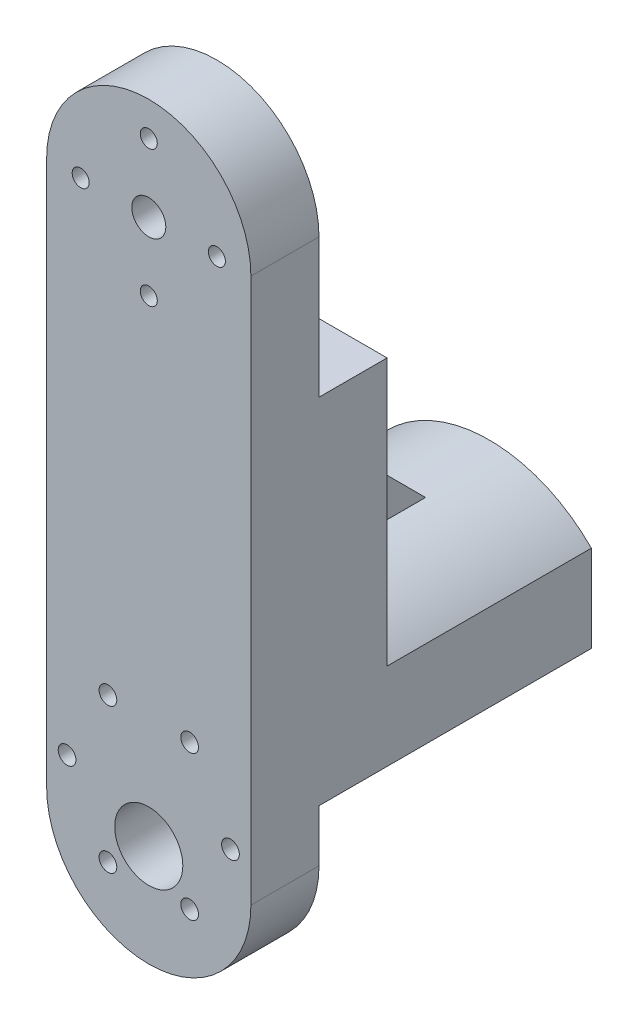
from build123d import *

# Parameters (mm, degrees)
SKETCH1_R           = 3.175
SKETCH1_R_2         = 6.35
SKETCH1_R_3         = 1.5875
BOSS_EXTRUDE1_DEPTH = 25.4
CUT_EXTRUDE1_REACH  = 40.1
SKETCH2_W           = 12.7
SKETCH2_H           = 44.958
CUT_EXTRUDE2_REACH  = 27.4
SKETCH3_R           = 1.651
BOSS_EXTRUDE2_DEPTH = 38.1
BOSS_EXTRUDE3_DEPTH = 12.7
BOSS_EXTRUDE4_DEPTH = 3.175


with BuildPart() as part:
    # Sketch1 → Boss-Extrude1 (new body)
    with BuildSketch(Plane.XY):
        with BuildLine():
            Line((-19.05, 50.8), (-19.05, -50.8))
            ThreePointArc((-19.05, -50.8), (0, -69.85), (19.05, -50.8))
            Line((19.05, -50.8), (19.05, 50.8))
            ThreePointArc((19.05, 50.8), (0, 69.85), (-19.05, 50.8))
        make_face()
        with Locations((0, 50.8)):
            Circle(SKETCH1_R, mode=Mode.SUBTRACT)
        with Locations((0, -50.8)):
            Circle(SKETCH1_R_2, mode=Mode.SUBTRACT)
        with Locations((0, 63.5)):
            Circle(SKETCH1_R_3, mode=Mode.SUBTRACT)
        with Locations((-12.7, 50.8)):
            Circle(SKETCH1_R_3, mode=Mode.SUBTRACT)
        with Locations((0, 38.1)):
            Circle(SKETCH1_R_3, mode=Mode.SUBTRACT)
        with Locations((12.7, 50.8)):
            Circle(SKETCH1_R_3, mode=Mode.SUBTRACT)
    extrude(amount=BOSS_EXTRUDE1_DEPTH)

    # Sketch2 → Cut-Extrude1 (cut, up to next)
    with BuildSketch(Plane(origin=(19.05, 0, 0), x_dir=(0, 0, -1), z_dir=(1, 0, 0)), mode=Mode.PRIVATE) as cut_extrude1_sk1:
        with Locations((-6.35, 47.371)):
            Rectangle(SKETCH2_W, SKETCH2_H)
    cut_extrude1_tool1 = extrude(cut_extrude1_sk1.sketch, amount=-CUT_EXTRUDE1_REACH, mode=Mode.PRIVATE) & part.part
    add(cut_extrude1_tool1.solids().sort_by_distance((19.05, 47.371, 6.35))[0], mode=Mode.SUBTRACT)
    # Sketch2 → Cut-Extrude1 (cut, up to next)
    with BuildSketch(Plane(origin=(19.05, 0, 0), x_dir=(0, 0, -1), z_dir=(1, 0, 0)), mode=Mode.PRIVATE) as cut_extrude1_sk2:
        with Locations((-6.35, -47.371)):
            Rectangle(SKETCH2_W, SKETCH2_H)
    cut_extrude1_tool2 = extrude(cut_extrude1_sk2.sketch, amount=-CUT_EXTRUDE1_REACH, mode=Mode.PRIVATE) & part.part
    add(cut_extrude1_tool2.solids().sort_by_distance((19.05, -47.371, 6.35))[0], mode=Mode.SUBTRACT)

    # Sketch3 → Cut-Extrude2 (cut, up to next)
    with BuildSketch(Plane(origin=(0, 0, 0), x_dir=(-1, 0, 0), z_dir=(0, 0, -1)), mode=Mode.PRIVATE) as cut_extrude2_sk1:
        with Locations((-7.62, -30.197275928)):
            Circle(SKETCH3_R)
    cut_extrude2_tool1 = extrude(cut_extrude2_sk1.sketch, amount=-CUT_EXTRUDE2_REACH, mode=Mode.PRIVATE) & part.part
    add(cut_extrude2_tool1.solids().sort_by_distance((7.62, -30.197276, 0))[0], mode=Mode.SUBTRACT)
    # Sketch3 → Cut-Extrude2 (cut, up to next)
    with BuildSketch(Plane(origin=(0, 0, 0), x_dir=(-1, 0, 0), z_dir=(0, 0, -1)), mode=Mode.PRIVATE) as cut_extrude2_sk2:
        with Locations((-15.24, -43.688)):
            Circle(SKETCH3_R)
    cut_extrude2_tool2 = extrude(cut_extrude2_sk2.sketch, amount=-CUT_EXTRUDE2_REACH, mode=Mode.PRIVATE) & part.part
    add(cut_extrude2_tool2.solids().sort_by_distance((15.24, -43.688, 0))[0], mode=Mode.SUBTRACT)
    # Sketch3 → Cut-Extrude2 (cut, up to next)
    with BuildSketch(Plane(origin=(0, 0, 0), x_dir=(-1, 0, 0), z_dir=(0, 0, -1)), mode=Mode.PRIVATE) as cut_extrude2_sk3:
        with Locations((-7.62, -57.178724072)):
            Circle(SKETCH3_R)
    cut_extrude2_tool3 = extrude(cut_extrude2_sk3.sketch, amount=-CUT_EXTRUDE2_REACH, mode=Mode.PRIVATE) & part.part
    add(cut_extrude2_tool3.solids().sort_by_distance((7.62, -57.178724, 0))[0], mode=Mode.SUBTRACT)
    # Sketch3 → Cut-Extrude2 (cut, up to next)
    with BuildSketch(Plane(origin=(0, 0, 0), x_dir=(-1, 0, 0), z_dir=(0, 0, -1)), mode=Mode.PRIVATE) as cut_extrude2_sk4:
        with Locations((7.62, -57.178724072)):
            Circle(SKETCH3_R)
    cut_extrude2_tool4 = extrude(cut_extrude2_sk4.sketch, amount=-CUT_EXTRUDE2_REACH, mode=Mode.PRIVATE) & part.part
    add(cut_extrude2_tool4.solids().sort_by_distance((-7.62, -57.178724, 0))[0], mode=Mode.SUBTRACT)
    # Sketch3 → Cut-Extrude2 (cut, up to next)
    with BuildSketch(Plane(origin=(0, 0, 0), x_dir=(-1, 0, 0), z_dir=(0, 0, -1)), mode=Mode.PRIVATE) as cut_extrude2_sk5:
        with Locations((15.24, -43.688)):
            Circle(SKETCH3_R)
    cut_extrude2_tool5 = extrude(cut_extrude2_sk5.sketch, amount=-CUT_EXTRUDE2_REACH, mode=Mode.PRIVATE) & part.part
    add(cut_extrude2_tool5.solids().sort_by_distance((-15.24, -43.688, 0))[0], mode=Mode.SUBTRACT)
    # Sketch3 → Cut-Extrude2 (cut, up to next)
    with BuildSketch(Plane(origin=(0, 0, 0), x_dir=(-1, 0, 0), z_dir=(0, 0, -1)), mode=Mode.PRIVATE) as cut_extrude2_sk6:
        with Locations((7.62, -30.197275928)):
            Circle(SKETCH3_R)
    cut_extrude2_tool6 = extrude(cut_extrude2_sk6.sketch, amount=-CUT_EXTRUDE2_REACH, mode=Mode.PRIVATE) & part.part
    add(cut_extrude2_tool6.solids().sort_by_distance((-7.62, -30.197276, 0))[0], mode=Mode.SUBTRACT)

    # Sketch5 → Boss-Extrude2 (add)
    with BuildSketch(Plane(origin=(0, 0, 0), x_dir=(-1, 0, 0), z_dir=(0, 0, -1))):
        with BuildLine():
            Line((-19.05, -41.097979346), (-19.05, -24.892))
            ThreePointArc((-19.05, -24.892), (0, -16.926234064), (19.05, -24.892))
            Line((19.05, -24.892), (19.05, -41.148))
            Line((19.05, -41.148), (18.324802864, -41.148))
            ThreePointArc((18.324802864, -41.148), (0, -25.188), (-18.324802864, -41.148))
            ThreePointArc((-18.324802864, -41.148), (-18.686539909, -41.110499348), (-19.05, -41.097979346))
        make_face()
    extrude(amount=BOSS_EXTRUDE2_DEPTH)

    # Sketch6 → Boss-Extrude3 (add)
    with BuildSketch(Plane.XY):
        with BuildLine():
            Line((-19.05, -24.892), (-19.05, -41.148))
            Line((-19.05, -41.148), (-18.324802864, -41.148))
            ThreePointArc((-18.324802864, -41.148), (0, -25.188), (18.324802864, -41.148))
            Line((18.324802864, -41.148), (19.05, -41.097979346))
            Line((19.05, -41.097979346), (19.05, -24.892))
            Line((19.05, -24.892), (-19.05, -24.892))
        make_face()
    extrude(amount=BOSS_EXTRUDE3_DEPTH)

    # Sketch7 → Boss-Extrude4 (add, symmetric)
    with BuildSketch(Plane(origin=(0, 0, 0), x_dir=(0, 0, -1), z_dir=(1, 0, 0))):
        Polygon((0, -19.466234064), (0, 5.933765936), (25.4, -19.466234064), align=None)
    extrude(amount=BOSS_EXTRUDE4_DEPTH, both=True)


solid = part.part
